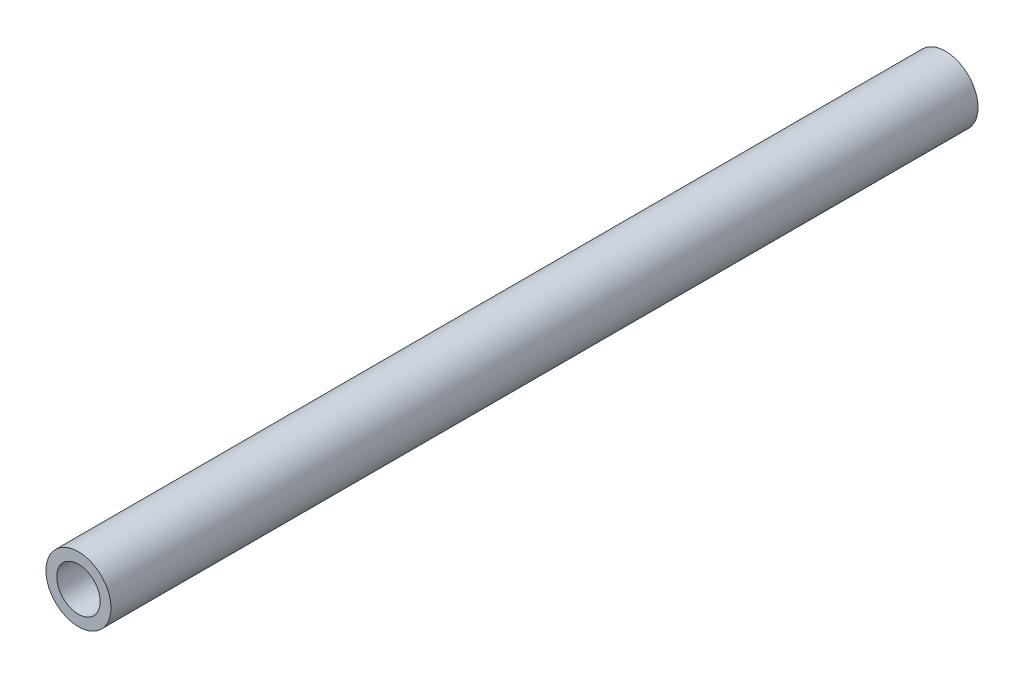
from build123d import *

# Parameters (mm, degrees)
SKETCH1_R           = 7.62
SKETCH1_R_2         = 5.08
BOSS_EXTRUDE1_DEPTH = 203.2


with BuildPart() as part:
    # Sketch1 → Boss-Extrude1 (new body)
    with BuildSketch(Plane.XY):
        Circle(SKETCH1_R)
        Circle(SKETCH1_R_2, mode=Mode.SUBTRACT)
    extrude(amount=BOSS_EXTRUDE1_DEPTH)


solid = part.part
